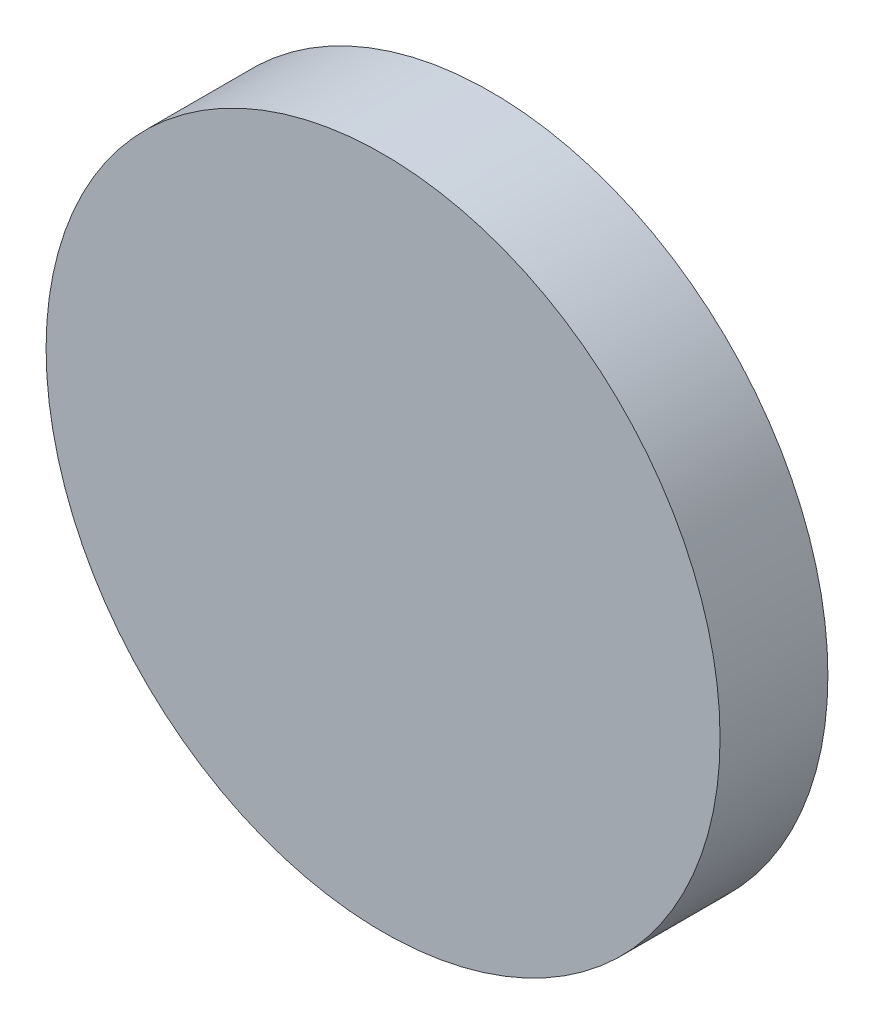
from build123d import *

# Parameters (mm, degrees)
SKETCH_1_R      = 6.25
EXTRUDE_1_DEPTH = 2


with BuildPart() as part:
    # 草图1 → 凸台-拉伸1 (new body)
    with BuildSketch(Plane.XY):
        Circle(SKETCH_1_R)
    extrude(amount=EXTRUDE_1_DEPTH)


solid = part.part
